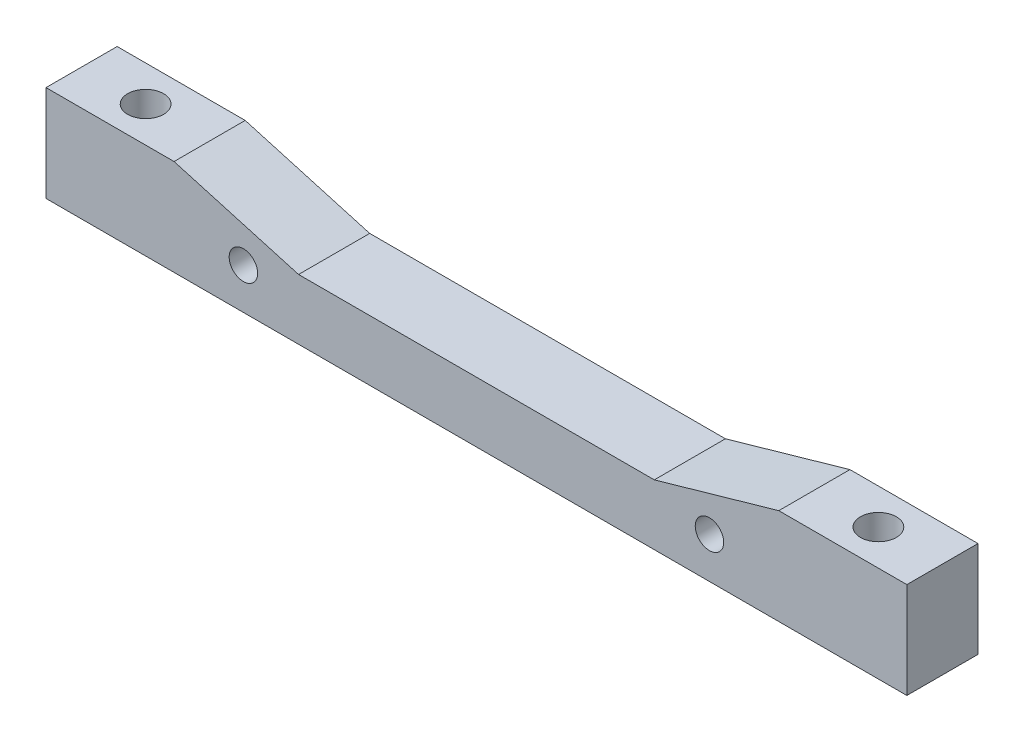
from build123d import *

# Parameters (mm, degrees)
CROQUIS1_W              = 121
CROQUIS1_H              = 10
SALIENTE_EXTRUIR1_DEPTH = 13.5
CROQUIS2_R              = 2.525
CORTAR_EXTRUIR1_DEPTH   = 8.05
CORTAR_EXTRUIR2_DEPTH   = 20
CROQUIS4_R              = 2
CORTAR_EXTRUIR3_DEPTH   = 20


with BuildPart() as part:
    # Croquis1 → Saliente-Extruir1 (new body)
    with BuildSketch(Plane(origin=(0, 0, 0), x_dir=(1, 0, 0), z_dir=(0, 1, 0))):
        with Locations((60.5, 5)):
            Rectangle(CROQUIS1_W, CROQUIS1_H)
    extrude(amount=SALIENTE_EXTRUIR1_DEPTH)

    # Croquis2 → Cortar-Extruir1 (cut)
    with BuildSketch(Plane(origin=(0, 13.5, 0), x_dir=(1, 0, 0), z_dir=(0, 1, 0))):
        with Locations((9, 5)):
            Circle(CROQUIS2_R)
        with Locations((112, 5)):
            Circle(CROQUIS2_R)
    extrude(amount=-CORTAR_EXTRUIR1_DEPTH, mode=Mode.SUBTRACT)

    # Croquis3 → Cortar-Extruir2 (cut)
    with BuildSketch(Plane.XY):
        Polygon((103, 13.5), (18, 13.5), (35.5, 8.5), (85.5, 8.5), align=None)
    extrude(amount=-CORTAR_EXTRUIR2_DEPTH, mode=Mode.SUBTRACT)

    # Croquis4 → Cortar-Extruir3 (cut)
    with BuildSketch(Plane.XY):
        with Locations((27.745, 5.76)):
            Circle(CROQUIS4_R)
        with Locations((93.255, 5.76)):
            Circle(CROQUIS4_R)
    extrude(amount=-CORTAR_EXTRUIR3_DEPTH, mode=Mode.SUBTRACT)


solid = part.part
